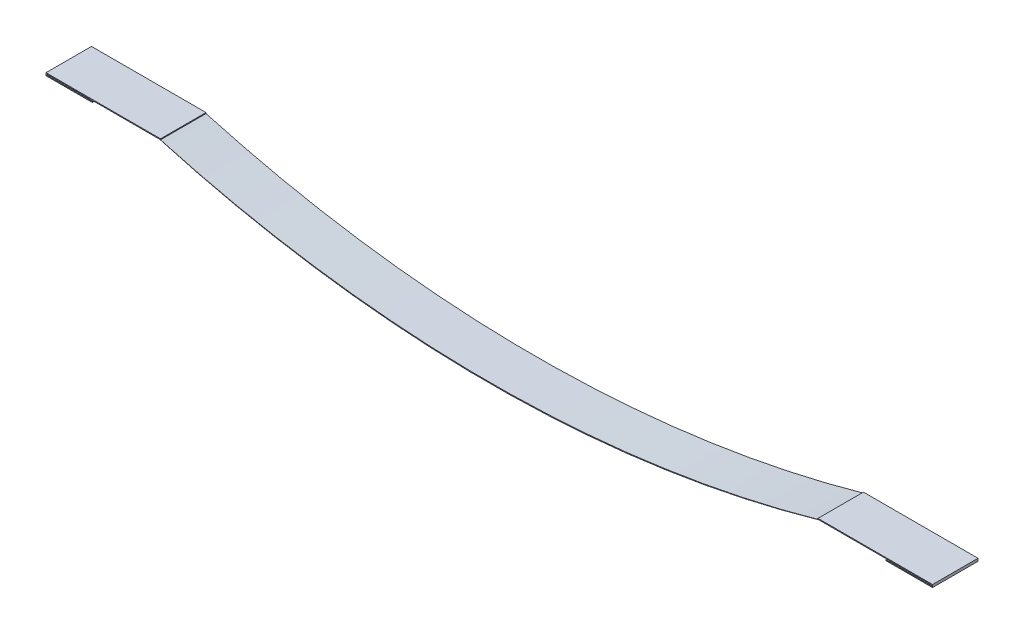
from build123d import *

# Parameters (mm, degrees)
SKETCH1_W           = 49.8
SKETCH1_H           = 1
BOSS_EXTRUDE1_DEPTH = 50.8


with BuildPart() as part:
    # Sketch1 → Boss-Extrude1 (new body)
    with BuildSketch(Plane.XY):
        with BuildLine():
            Line((-444.5, 1), (-495.3, 1))
            Line((-495.3, 1), (-495.3, -2))
            Line((-495.3, -2), (-444.5, -2))
            Line((-444.5, -2), (-443.5, -2))
            Line((-443.5, -2), (-443.5, 0))
            Line((-443.5, 0), (-368.3, 0))
            ThreePointArc((-368.3, 0), (0, -51.8), (368.3, 0))
            Line((368.3, 0), (443.5, 0))
            Line((443.5, 0), (443.5, -2))
            Line((443.5, -2), (444.5, -2))
            Line((444.5, -2), (495.3, -2))
            Line((495.3, -2), (495.3, 1))
            Line((495.3, 1), (444.5, 1))
            Line((444.5, 1), (368.3, 1))
            Line((368.3, 1), (367.3, 1))
            Line((367.3, 1), (367.3, 0))
            ThreePointArc((367.3, 0), (0, -50.8), (-367.3, 0))
            Line((-367.3, 0), (-367.3, 1))
            Line((-367.3, 1), (-368.3, 1))
            Line((-368.3, 1), (-444.5, 1))
        make_face()
        with Locations((-469.4, -0.5)):
            Rectangle(SKETCH1_W, SKETCH1_H, mode=Mode.SUBTRACT)
        with Locations((469.4, -0.5)):
            Rectangle(SKETCH1_W, SKETCH1_H, mode=Mode.SUBTRACT)
    extrude(amount=BOSS_EXTRUDE1_DEPTH)


solid = part.part
